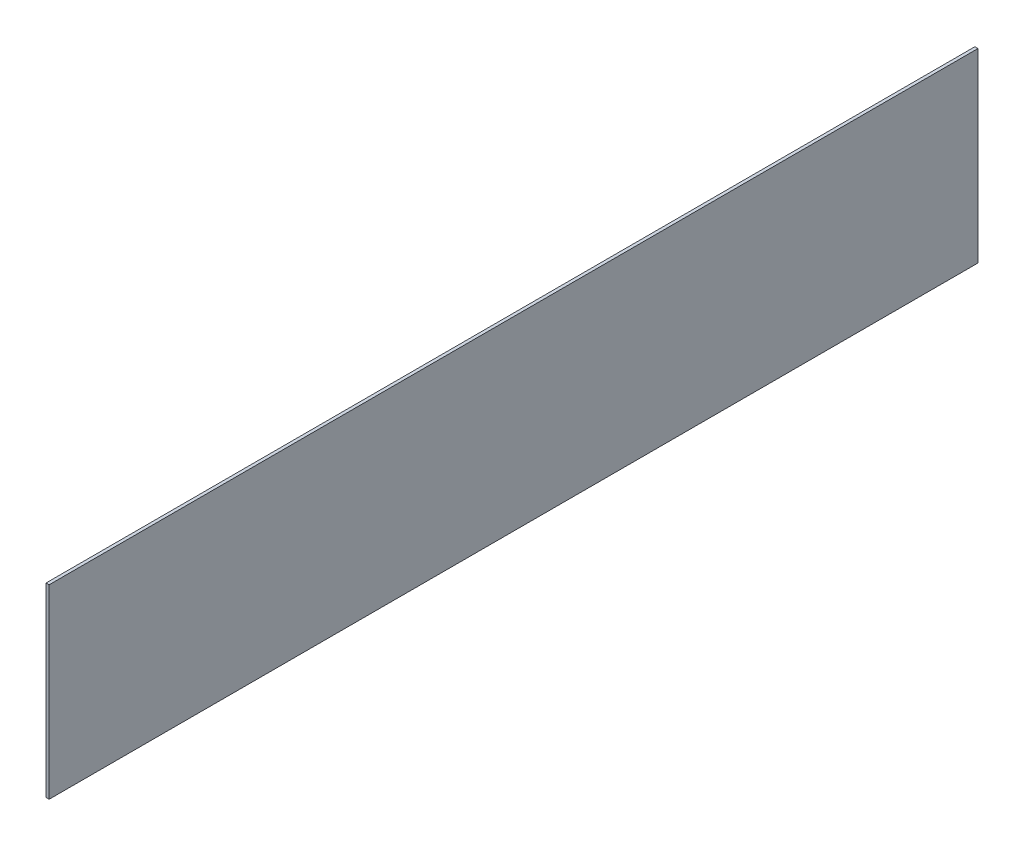
from build123d import *

# Parameters (mm, degrees)
SKIZZE1_W                    = 1
SKIZZE1_H                    = 60
LINEAR_AUSTRAGEN_D_NN1_DEPTH = 300


with BuildPart() as part:
    # Skizze1 → Linear-Austragen-Dünn1 (new body)
    with BuildSketch(Plane.XY):
        with Locations((0.5, 30)):
            Rectangle(SKIZZE1_W, SKIZZE1_H)
    extrude(amount=LINEAR_AUSTRAGEN_D_NN1_DEPTH)


solid = part.part
